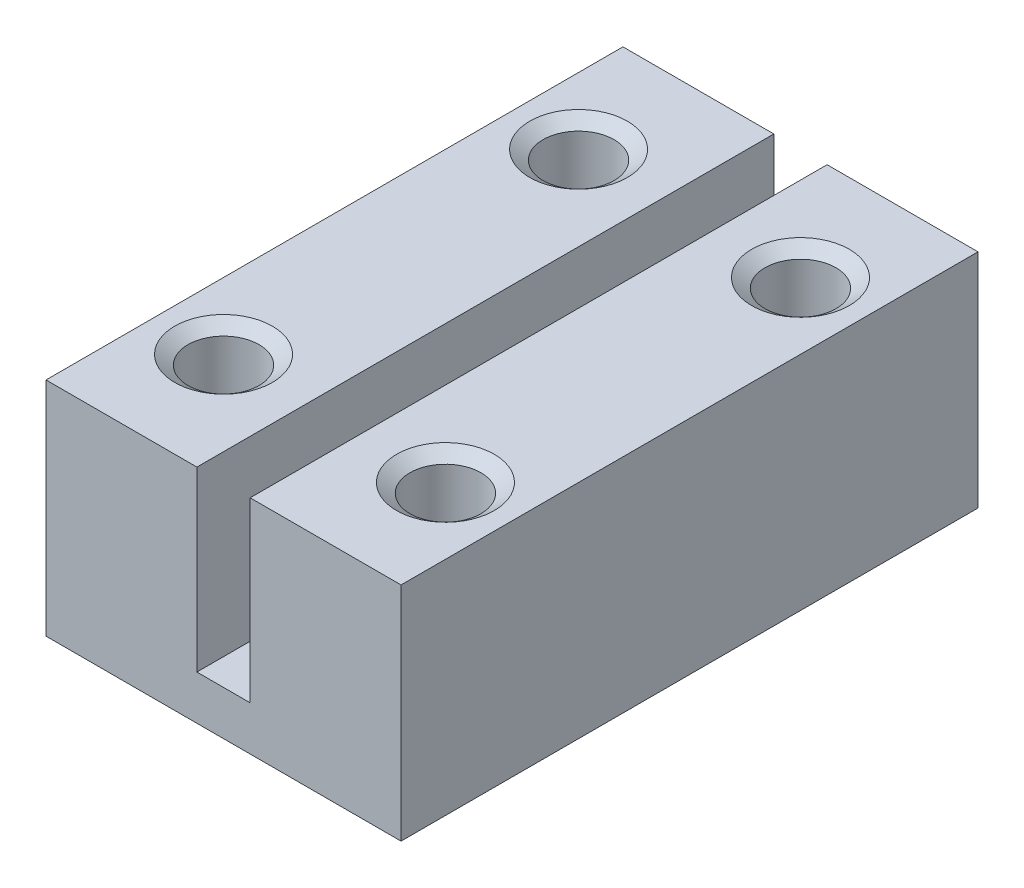
from build123d import *

# Parameters (mm, degrees)
EXTRUDE_1_DEPTH    = 13
M2X0_41_AT_2_COUNT = 2
M2X0_41_AT_2_PITCH = 5
M2X0_41_AT_3_COUNT = 2
M2X0_41_AT_3_PITCH = 9.433981132
M2X0_41_AT_4_COUNT = 2
M2X0_41_AT_4_PITCH = 8


with BuildPart() as part:
    # Эскиз1 → Бобышка-Вытянуть1 (new body)
    with BuildSketch(Plane.XY):
        Polygon((-4, 5), (-0.6, 5), (-0.6, 1), (0.6, 1), (0.6, 5), (4, 5), (4, 0), (-4, 0), align=None)
    extrude(amount=EXTRUDE_1_DEPTH)

    # Эскиз2 → Отверстие обработанное метчиком M2x0.41 (revolve, cut)
    with BuildSketch(Plane(origin=(-2.5, 0, 10.5), x_dir=(0, 0, -1), z_dir=(1, 0, 0))):
        Polygon((0, 0), (0, 5), (1.1, 5), (0.8, 4.789937739), (0.8, 0.3), (1.1, 0), align=None)
    m2x0_41 = revolve(axis=Axis((-2.5, -6.35, 10.5), (0, 1, 0)), mode=Mode.SUBTRACT)

    # Отверстие обработанное метчиком M2x0.41 at 2: Отверстие обработанное метчиком M2x0.41 ×2
    with Locations(*[(i * M2X0_41_AT_2_PITCH, 0, 0) for i in range(1, M2X0_41_AT_2_COUNT)]):
        add(m2x0_41, mode=Mode.SUBTRACT)

    # Отверстие обработанное метчиком M2x0.41 at 3: Отверстие обработанное метчиком M2x0.41 ×2
    with Locations(*[Vector(0.52999894, 0, -0.847998304) * (i * M2X0_41_AT_3_PITCH) for i in range(1, M2X0_41_AT_3_COUNT)]):
        add(m2x0_41, mode=Mode.SUBTRACT)

    # Отверстие обработанное метчиком M2x0.41 at 4: Отверстие обработанное метчиком M2x0.41 ×2
    with Locations(*[(0, 0, -i * M2X0_41_AT_4_PITCH) for i in range(1, M2X0_41_AT_4_COUNT)]):
        add(m2x0_41, mode=Mode.SUBTRACT)


solid = part.part
